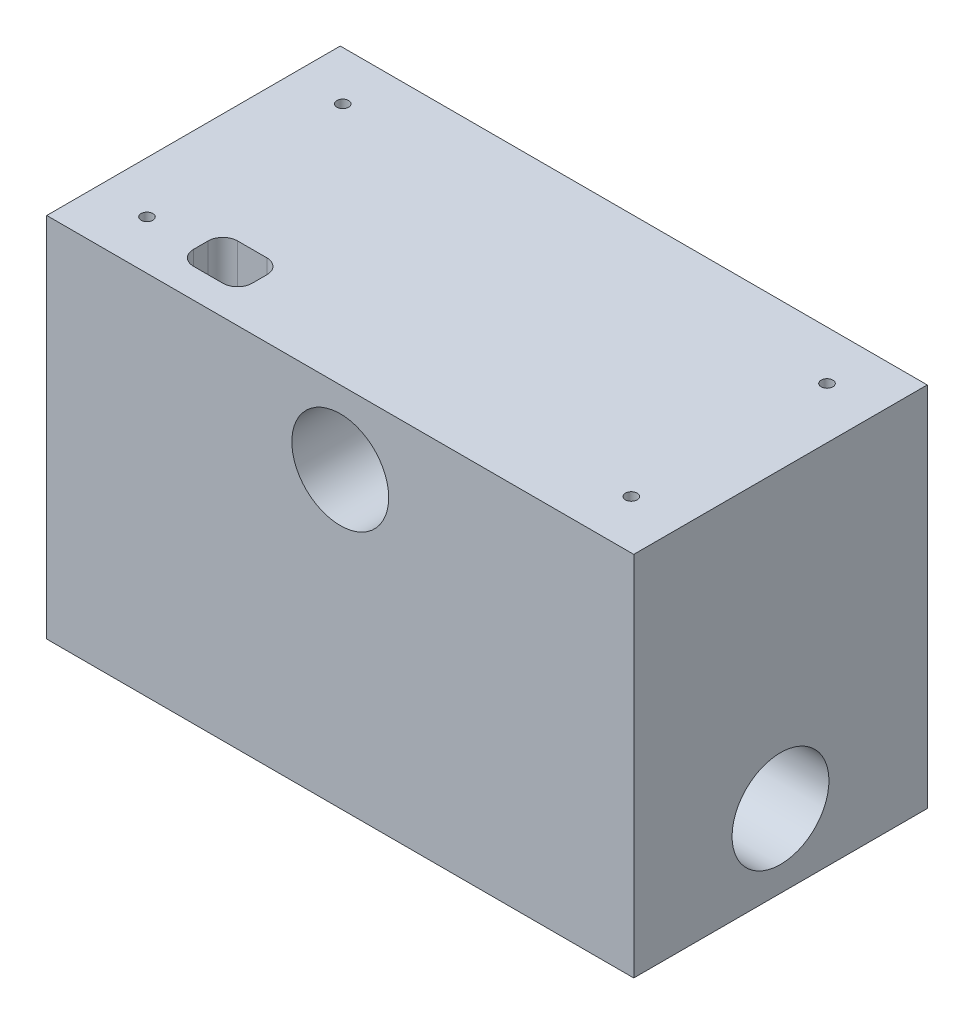
from build123d import *

# Parameters (mm, degrees)
SKETCH1_W           = 50.8
SKETCH1_H           = 31.75
BOSS_EXTRUDE1_DEPTH = 25.4
SKETCH4_R           = 4.191
CUT_EXTRUDE1_DEPTH  = 152.4
SKETCH5_R           = 4.191
CUT_EXTRUDE2_DEPTH  = 25.4
SKETCH7_R           = 0.508
CUT_EXTRUDE3_DEPTH  = 7.62
SKETCH9_W           = 5.08
SKETCH9_H           = 3.81
CUT_EXTRUDE5_DEPTH  = 152.4
FILLET1_R           = 1.27


with BuildPart() as part:
    # Sketch1 → Boss-Extrude1 (new body)
    with BuildSketch(Plane.XY):
        Rectangle(SKETCH1_W, SKETCH1_H)
    extrude(amount=BOSS_EXTRUDE1_DEPTH)

    # Sketch4 → Cut-Extrude1 (cut)
    with BuildSketch(Plane.ZY.offset(25.4)):
        with Locations((12.7, -9.525)):
            Circle(SKETCH4_R)
    extrude(amount=-CUT_EXTRUDE1_DEPTH, mode=Mode.SUBTRACT)

    # Sketch5 → Cut-Extrude2 (cut)
    with BuildSketch(Plane.XY.offset(25.4)):
        with Locations((0, 9.525)):
            Circle(SKETCH5_R)
    extrude(amount=-CUT_EXTRUDE2_DEPTH, mode=Mode.SUBTRACT)

    # Sketch7 → Cut-Extrude3 (cut)
    with BuildSketch(Plane(origin=(0, 15.875, 0), x_dir=(1, 0, 0), z_dir=(0, 1, 0))):
        with Locations((-20.955, -4.2291)):
            Circle(SKETCH7_R)
        with Locations((-20.955, -21.1709)):
            Circle(SKETCH7_R)
        with Locations((20.955, -4.2291)):
            Circle(SKETCH7_R)
        with Locations((20.955, -21.1709)):
            Circle(SKETCH7_R)
    extrude(amount=-CUT_EXTRUDE3_DEPTH, mode=Mode.SUBTRACT)

    # Sketch9 → Cut-Extrude5 (cut)
    with BuildSketch(Plane(origin=(0, 15.875, 0), x_dir=(1, 0, 0), z_dir=(0, 1, 0))):
        with Locations((-13.97, -20.955)):
            Rectangle(SKETCH9_W, SKETCH9_H)
    extrude(amount=-CUT_EXTRUDE5_DEPTH, mode=Mode.SUBTRACT)

    # Fillet1
    fillet1_edges = [part.edges().sort_by_distance(p)[0] for p in [
        (-16.51, 0, 22.86),
        (-16.51, 0, 19.05),
        (-11.43, 0, 19.05),
        (-11.43, 0, 22.86),
    ]]
    fillet(fillet1_edges, radius=FILLET1_R)


solid = part.part
